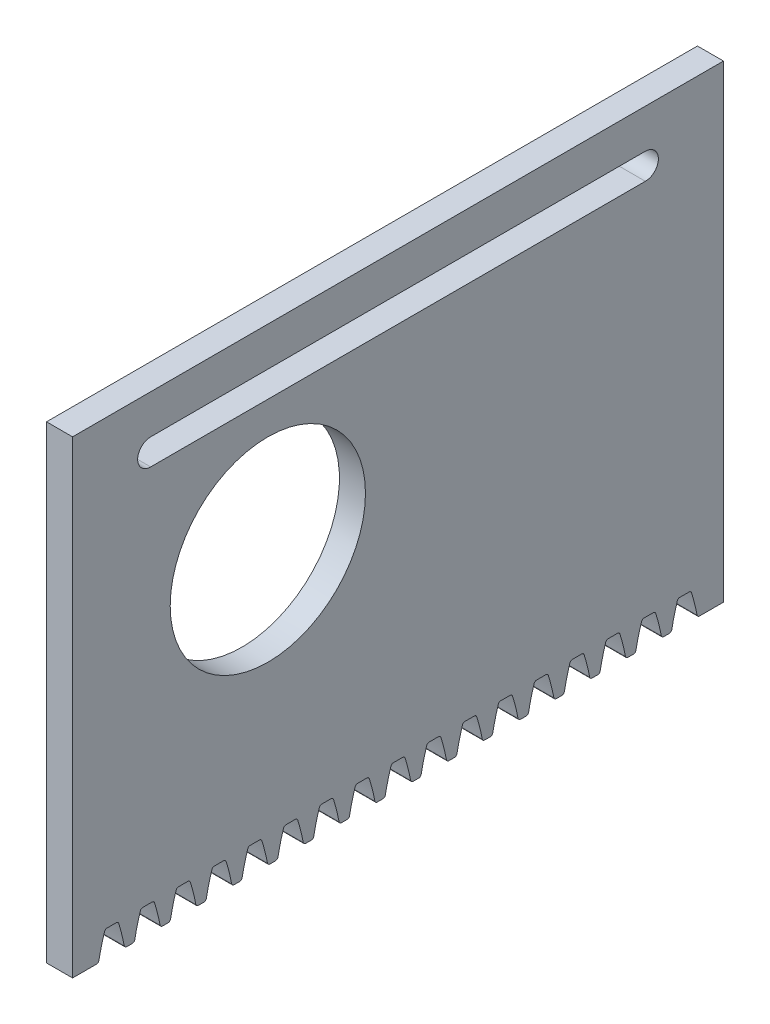
from build123d import *

# Parameters (mm, degrees)
BOSS_EXTRUDE1_DEPTH        = 2
CUT_EXTRUDE2_DEPTH         = 3
FILLET1_R                  = 0.2
LPATTERN1_COUNT            = 9
LPATTERN1_PITCH            = 2.75
FILLET1_OF_LPATTERN1_R     = 0.2
LPATTERN1_COL_COUNT        = 9
LPATTERN1_COL_PITCH        = 2.75
FILLET1_OF_LPATTERN1_COL_R = 0.2
SKETCH4_R                  = 7.5
CUT_EXTRUDE3_DEPTH         = 10
CUT_EXTRUDE4_DEPTH         = 10


with BuildPart() as part:
    # Sketch1 → Boss-Extrude1 (new body)
    with BuildSketch(Plane(origin=(0, 0, 0), x_dir=(0, 0, -1), z_dir=(1, 0, 0))):
        Polygon((-12.435218728, 30), (-12.435218728, -6), (20, -6), (37.564781272, -6), (37.564781272, 30), align=None)
    extrude(amount=BOSS_EXTRUDE1_DEPTH)

    # Sketch3 → Cut-Extrude2 (cut, through all)
    with BuildSketch(Plane.ZY):
        with BuildLine():
            Line((-13.064781272, -4), (-12.064781272, -4))
            ThreePointArc((-12.064781272, -4), (-11.780381399, -4.991400032), (-11.564781272, -6))
            Line((-11.564781272, -6), (-13.564781272, -6))
            ThreePointArc((-13.564781272, -6), (-13.349181144, -4.991400032), (-13.064781272, -4))
        make_face()
    cut_extrude2 = extrude(amount=-CUT_EXTRUDE2_DEPTH, mode=Mode.SUBTRACT)

    # Fillet1
    fillet1_edges = [part.edges().sort_by_distance(p)[0] for p in [
        (1, -6, -13.564781272),
        (1, -4, -13.064781272),
        (1, -4, -12.064781272),
        (1, -6, -11.564781272),
    ]]
    fillet(fillet1_edges, radius=FILLET1_R)

    # LPattern1: Cut-Extrude2 ×9
    with Locations(*[(0, 0, i * LPATTERN1_PITCH) for i in range(1, LPATTERN1_COUNT)]):
        add(cut_extrude2, mode=Mode.SUBTRACT)

    # Fillet1 of LPattern1
    fillet1_of_lpattern1_edges = [part.edges().sort_by_distance(p)[0] for p in [
        (1, -6, -10.814781272),
        (1, -4, -10.314781272),
        (1, -4, -9.314781272),
        (1, -6, -8.814781272),
        (1, -6, -8.064781272),
        (1, -4, -7.564781272),
        (1, -4, -6.564781272),
        (1, -6, -6.064781272),
        (1, -6, -5.314781272),
        (1, -4, -4.814781272),
        (1, -4, -3.814781272),
        (1, -6, -3.314781272),
        (1, -6, -2.564781272),
        (1, -4, -2.064781272),
        (1, -4, -1.064781272),
        (1, -6, -0.564781272),
        (1, -6, 0.185218728),
        (1, -4, 0.685218728),
        (1, -4, 1.685218728),
        (1, -6, 2.185218728),
        (1, -6, 2.935218728),
        (1, -4, 3.435218728),
        (1, -4, 4.435218728),
        (1, -6, 4.935218728),
        (1, -6, 5.685218728),
        (1, -4, 6.185218728),
        (1, -4, 7.185218728),
        (1, -6, 7.685218728),
        (1, -6, 8.435218728),
        (1, -4, 8.935218728),
        (1, -4, 9.935218728),
        (1, -6, 10.435218728),
    ]]
    fillet(fillet1_of_lpattern1_edges, radius=FILLET1_OF_LPATTERN1_R)

    # LPattern1 col: Cut-Extrude2 ×9
    with Locations(*[(0, 0, -i * LPATTERN1_COL_PITCH) for i in range(1, LPATTERN1_COL_COUNT)]):
        add(cut_extrude2, mode=Mode.SUBTRACT)

    # Fillet1 of LPattern1 col
    fillet1_of_lpattern1_col_edges = [part.edges().sort_by_distance(p)[0] for p in [
        (1, -6, -16.314781272),
        (1, -4, -15.814781272),
        (1, -4, -14.814781272),
        (1, -6, -14.314781272),
        (1, -6, -19.064781272),
        (1, -4, -18.564781272),
        (1, -4, -17.564781272),
        (1, -6, -17.064781272),
        (1, -6, -21.814781272),
        (1, -4, -21.314781272),
        (1, -4, -20.314781272),
        (1, -6, -19.814781272),
        (1, -6, -24.564781272),
        (1, -4, -24.064781272),
        (1, -4, -23.064781272),
        (1, -6, -22.564781272),
        (1, -6, -27.314781272),
        (1, -4, -26.814781272),
        (1, -4, -25.814781272),
        (1, -6, -25.314781272),
        (1, -6, -30.064781272),
        (1, -4, -29.564781272),
        (1, -4, -28.564781272),
        (1, -6, -28.064781272),
        (1, -6, -32.814781272),
        (1, -4, -32.314781272),
        (1, -4, -31.314781272),
        (1, -6, -30.814781272),
        (1, -6, -35.564781272),
        (1, -4, -35.064781272),
        (1, -4, -34.064781272),
        (1, -6, -33.564781272),
    ]]
    fillet(fillet1_of_lpattern1_col_edges, radius=FILLET1_OF_LPATTERN1_COL_R)

    # Sketch4 → Cut-Extrude3 (cut)
    with BuildSketch(Plane.ZY):
        with Locations((-2.564781272, 15)):
            Circle(SKETCH4_R)
    extrude(amount=-CUT_EXTRUDE3_DEPTH, mode=Mode.SUBTRACT)

    # Sketch5 → Cut-Extrude4 (cut)
    with BuildSketch(Plane.ZY):
        with BuildLine():
            Line((-31.564781272, 27), (6.435218728, 27))
            ThreePointArc((6.435218728, 27), (7.435218728, 26), (6.435218728, 25))
            Line((6.435218728, 25), (-31.564781272, 25))
            ThreePointArc((-31.564781272, 25), (-32.564781272, 26), (-31.564781272, 27))
        make_face()
    extrude(amount=-CUT_EXTRUDE4_DEPTH, mode=Mode.SUBTRACT)


solid = part.part
